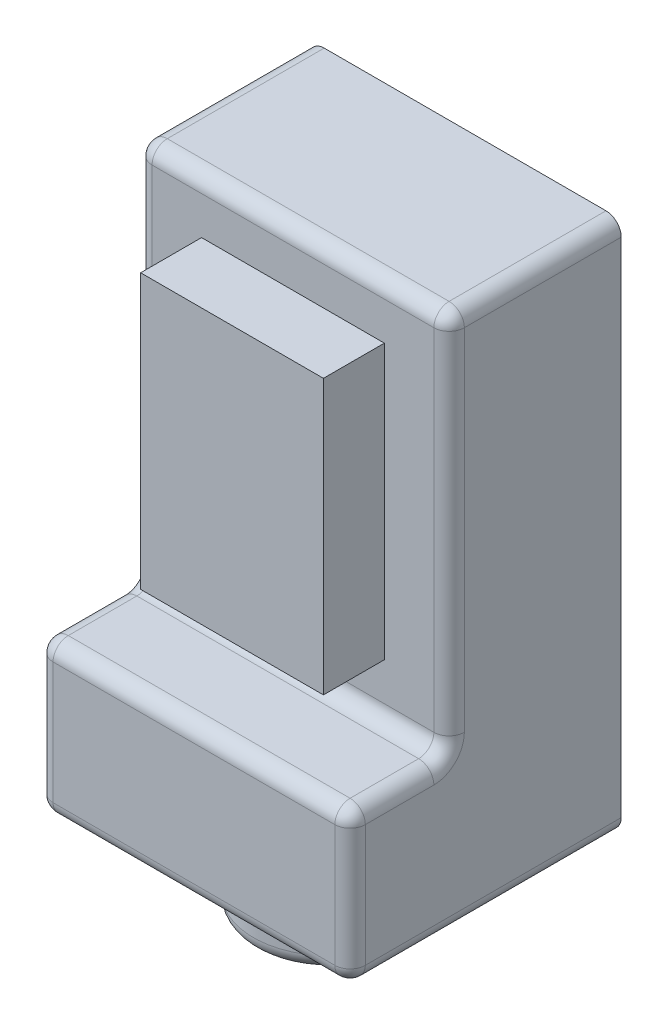
from build123d import *

# Parameters (mm, degrees)
SKETCH_1_W          = 20.5
SKETCH_1_H          = 35
EXTRUDE_1_DEPTH     = 17.8
SKETCH_3_R          = 3
EXTRUDE_2_DEPTH     = 2
SKETCH_4_R          = 5
EXTRUDE_3_DEPTH     = 3
SKETCH_5_W          = 20.5
SKETCH_5_H          = 25
CUT_EXTRUDE_1_DEPTH = 6.5
FILLET_1_R          = 1
SKETCH_6_W          = 12
SKETCH_6_H          = 18
EXTRUDE_4_DEPTH     = 4


with BuildPart() as part:
    # 草圖1 → 填料-伸長1 (new body)
    with BuildSketch(Plane.XY):
        Rectangle(SKETCH_1_W, SKETCH_1_H)
    extrude(amount=EXTRUDE_1_DEPTH)

    # 草圖3 → 填料-伸長2 (add)
    with BuildSketch(Plane.XZ.offset(17.5)):
        with Locations((0, 8.9)):
            Circle(SKETCH_3_R)
    extrude(amount=EXTRUDE_2_DEPTH)

    # 草圖4 → 填料-伸長3 (add)
    with BuildSketch(Plane.XZ.offset(19.5)):
        with Locations((0, 8.9)):
            Circle(SKETCH_4_R)
    extrude(amount=EXTRUDE_3_DEPTH)

    # 草圖5 → 除料-伸長1 (cut)
    with BuildSketch(Plane.XY.offset(17.8)):
        with Locations((0, 5)):
            Rectangle(SKETCH_5_W, SKETCH_5_H)
    extrude(amount=-CUT_EXTRUDE_1_DEPTH, mode=Mode.SUBTRACT)

    # 圓角1
    fillet_1_edges = [part.edges().sort_by_distance(p)[0] for p in [
        (0, -17.5, 17.8),
        (-5, -22.5, 8.9),
        (-10.25, -12.5, 17.8),
        (-10.25, 17.5, 5.65),
        (10.25, 17.5, 5.65),
        (-10.25, 5, 11.3),
        (-10.25, -7.5, 14.55),
        (0, 17.5, 11.3),
        (10.25, 5, 11.3),
        (0, -7.5, 11.3),
        (10.25, -7.5, 14.55),
        (0, -7.5, 17.8),
        (10.25, -12.5, 17.8),
        (10.25, -17.5, 8.9),
        (-10.25, -17.5, 8.9),
    ]]
    fillet(fillet_1_edges, radius=FILLET_1_R)

    # 草圖6 → 填料-伸長4 (add)
    with BuildSketch(Plane.XY.offset(11.3)):
        with Locations((0, 5)):
            Rectangle(SKETCH_6_W, SKETCH_6_H)
    extrude(amount=EXTRUDE_4_DEPTH)


solid = part.part
